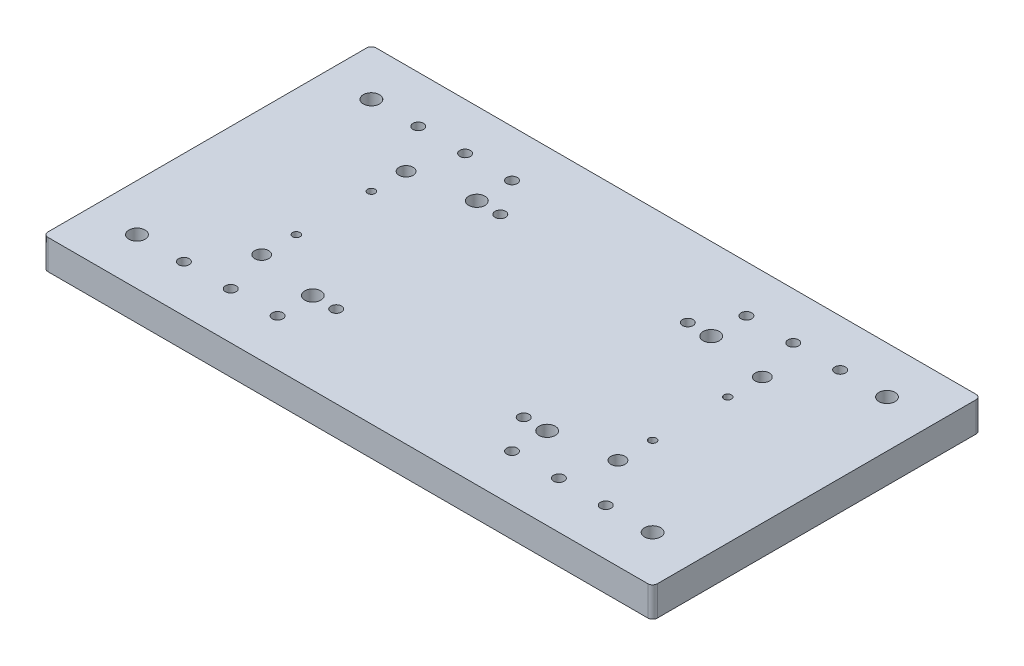
from build123d import *

# Parameters (mm, degrees)
SKETCH1_W             = 130
SKETCH1_H             = 70
SKETCH1_R             = 1.725
SKETCH1_R_2           = 1.13
SKETCH1_R_3           = 0.8
SKETCH1_R_4           = 1.5
BOSS_EXTRUDE1_DEPTH   = 6.35
F_4_40_TAPPED_HOLE1_D = 2.2606
FILLET1_R             = 1


with BuildPart() as part:
    # Sketch1 → Boss-Extrude1 (new body)
    with BuildSketch(Plane(origin=(0, 0, 0), x_dir=(1, 0, 0), z_dir=(0, 1, 0))):
        with Locations((65, -35)):
            Rectangle(SKETCH1_W, SKETCH1_H)
        with Locations((10, -10)):
            Circle(SKETCH1_R, mode=Mode.SUBTRACT)
        with Locations((20, -10)):
            Circle(SKETCH1_R_2, mode=Mode.SUBTRACT)
        with Locations((30, -10)):
            Circle(SKETCH1_R_2, mode=Mode.SUBTRACT)
        with Locations((40, -10)):
            Circle(SKETCH1_R_2, mode=Mode.SUBTRACT)
        with Locations((45, -17.5)):
            Circle(SKETCH1_R_2, mode=Mode.SUBTRACT)
        with Locations((40, -17.5)):
            Circle(SKETCH1_R, mode=Mode.SUBTRACT)
        with Locations((27, -27)):
            Circle(SKETCH1_R_3, mode=Mode.SUBTRACT)
        with Locations((27, -19.6)):
            Circle(SKETCH1_R_4, mode=Mode.SUBTRACT)
        with Locations((27, -43)):
            Circle(SKETCH1_R_3, mode=Mode.SUBTRACT)
        with Locations((27, -50.4)):
            Circle(SKETCH1_R_4, mode=Mode.SUBTRACT)
        with Locations((45, -52.5)):
            Circle(SKETCH1_R_2, mode=Mode.SUBTRACT)
        with Locations((40, -52.5)):
            Circle(SKETCH1_R, mode=Mode.SUBTRACT)
        with Locations((40, -60)):
            Circle(SKETCH1_R_2, mode=Mode.SUBTRACT)
        with Locations((30, -60)):
            Circle(SKETCH1_R_2, mode=Mode.SUBTRACT)
        with Locations((20, -60)):
            Circle(SKETCH1_R_2, mode=Mode.SUBTRACT)
        with Locations((10, -60)):
            Circle(SKETCH1_R, mode=Mode.SUBTRACT)
        with Locations((120, -60)):
            Circle(SKETCH1_R, mode=Mode.SUBTRACT)
        with Locations((110, -60)):
            Circle(SKETCH1_R_2, mode=Mode.SUBTRACT)
        with Locations((100, -60)):
            Circle(SKETCH1_R_2, mode=Mode.SUBTRACT)
        with Locations((90, -60)):
            Circle(SKETCH1_R_2, mode=Mode.SUBTRACT)
        with Locations((85, -52.5)):
            Circle(SKETCH1_R_2, mode=Mode.SUBTRACT)
        with Locations((90, -52.5)):
            Circle(SKETCH1_R, mode=Mode.SUBTRACT)
        with Locations((103, -43)):
            Circle(SKETCH1_R_3, mode=Mode.SUBTRACT)
        with Locations((103, -50.4)):
            Circle(SKETCH1_R_4, mode=Mode.SUBTRACT)
        with Locations((103, -19.6)):
            Circle(SKETCH1_R_4, mode=Mode.SUBTRACT)
        with Locations((103, -27)):
            Circle(SKETCH1_R_3, mode=Mode.SUBTRACT)
        with Locations((85, -17.5)):
            Circle(SKETCH1_R_2, mode=Mode.SUBTRACT)
        with Locations((90, -17.5)):
            Circle(SKETCH1_R, mode=Mode.SUBTRACT)
        with Locations((90, -10)):
            Circle(SKETCH1_R_2, mode=Mode.SUBTRACT)
        with Locations((100, -10)):
            Circle(SKETCH1_R_2, mode=Mode.SUBTRACT)
        with Locations((110, -10)):
            Circle(SKETCH1_R_2, mode=Mode.SUBTRACT)
        with Locations((120, -10)):
            Circle(SKETCH1_R, mode=Mode.SUBTRACT)
    extrude(amount=BOSS_EXTRUDE1_DEPTH)

    # #4-40 Tapped Hole1 (through all)
    with Locations(Plane(origin=(40, 6.35, 10), x_dir=(0, 0, 1), z_dir=(0, 1, 0))):
        with Locations((0, 0), (0, -10), (0, -20), (0, 50), (50, 70), (50, 60), (50, 50), (50, 0), (50, -10), (50, -20), (0, 70), (0, 60), (7.5, 5), (7.5, 45), (42.5, 45), (42.5, 5)):
            Hole(F_4_40_TAPPED_HOLE1_D / 2)

    # Fillet1
    fillet1_edges = [part.edges().sort_by_distance(p)[0] for p in [
        (130, 3.175, 70),
        (0, 3.175, 70),
        (0, 3.175, 0),
        (130, 3.175, 0),
    ]]
    fillet(fillet1_edges, radius=FILLET1_R)


solid = part.part
